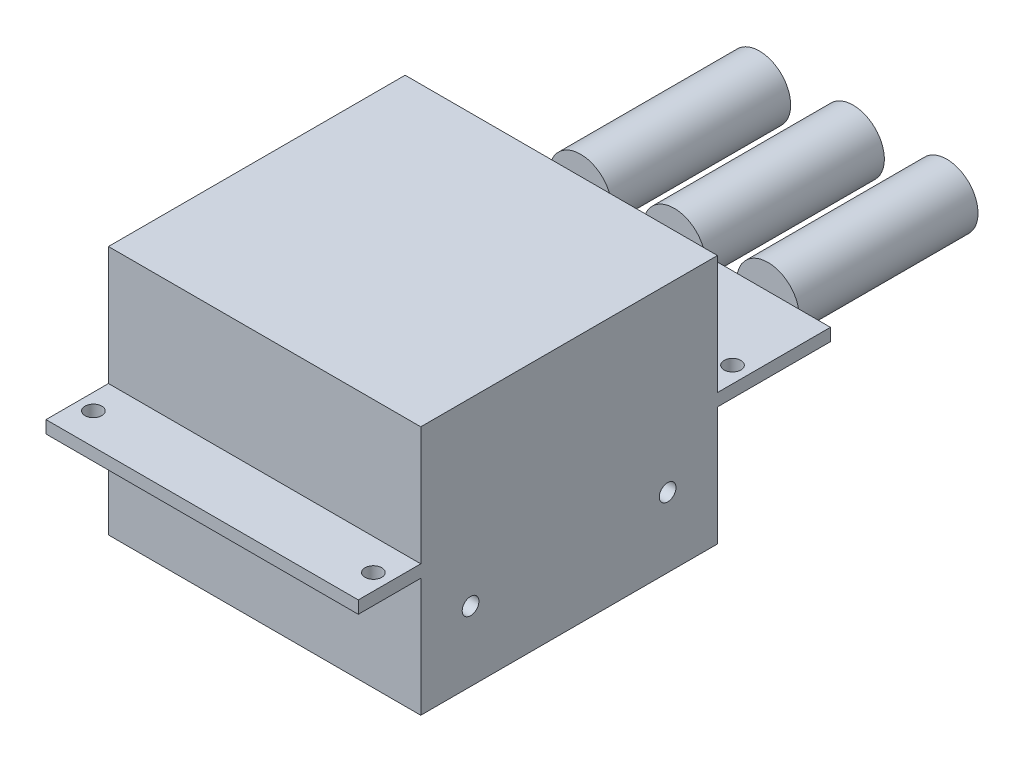
from build123d import *

# Parameters (mm, degrees)
SKETCH1_W               = 63.5
SKETCH1_H               = 50.8
BOSS_EXTRUDE1_DEPTH     = 96
SKETCH2_R               = 6.35
BOSS_EXTRUDE5_DEPTH     = 36.36
SKETCH3_W               = 12.7
SKETCH3_H               = 24.13
SKETCH3_W_2             = 22.975
CUT_EXTRUDE1_DEPTH      = 64.5
SKETCH4_R               = 1.7
CUT_EXTRUDE2_DEPTH      = 2.54
MIRROR3_COPY_1_SKETCH_R = 1.7
MIRROR3_COPY_1_DEPTH    = 2.54
SKETCH5_R               = 1.7
CUT_EXTRUDE3_DEPTH      = 64.5


with BuildPart() as part:
    # Sketch1 → Boss-Extrude1 (new body)
    with BuildSketch(Plane.XY):
        Rectangle(SKETCH1_W, SKETCH1_H)
    extrude(amount=-BOSS_EXTRUDE1_DEPTH)

    # Sketch2 → Boss-Extrude5 (add)
    with BuildSketch(Plane(origin=(0, 0, -96), x_dir=(-1, 0, 0), z_dir=(0, 0, -1))):
        Circle(SKETCH2_R)
        with Locations((-19.05, 0)):
            Circle(SKETCH2_R)
        with Locations((19.05, 0)):
            Circle(SKETCH2_R)
    extrude(amount=BOSS_EXTRUDE5_DEPTH)

    # Sketch3 → Cut-Extrude1 (cut, through all)
    with BuildSketch(Plane(origin=(31.75, 0, 0), x_dir=(0, 0, -1), z_dir=(1, 0, 0))):
        with Locations((6.35, -13.335)):
            Rectangle(SKETCH3_W, SKETCH3_H)
        with Locations((84.5125, -13.335)):
            Rectangle(SKETCH3_W_2, SKETCH3_H)
    cut_extrude1 = extrude(amount=-CUT_EXTRUDE1_DEPTH, mode=Mode.SUBTRACT)

    # Mirror1: Cut-Extrude1 across plane
    add(cut_extrude1.mirror(Plane.ZX), mode=Mode.SUBTRACT)

    # Sketch4 → Cut-Extrude2 (cut)
    with BuildSketch(Plane(origin=(0, 1.27, 0), x_dir=(1, 0, 0), z_dir=(0, 1, 0))):
        with Locations((-28.4625, 79.375)):
            Circle(SKETCH4_R)
    cut_extrude2 = extrude(amount=-CUT_EXTRUDE2_DEPTH, mode=Mode.SUBTRACT)

    # Mirror2: Cut-Extrude2 across plane
    add(cut_extrude2.mirror(Plane(origin=(0, 0, 0), x_dir=(0, 0, 1), z_dir=(1, 0, 0))), mode=Mode.SUBTRACT)

    # Mirror3: Cut-Extrude2 across plane
    add(cut_extrude2.mirror(Plane(origin=(0, 0, -42.8625), x_dir=(1, 0, 0), z_dir=(0, 0, -1))), mode=Mode.SUBTRACT)

    # Mirror3 copy 1 sketch → Mirror3 copy 1 (cut)
    with BuildSketch(Plane(origin=(0, 1.27, -85.725), x_dir=(-1, 0, 0), z_dir=(0, 1, 0))):
        with Locations((-28.4625, 79.375)):
            Circle(MIRROR3_COPY_1_SKETCH_R)
    extrude(amount=-MIRROR3_COPY_1_DEPTH, mode=Mode.SUBTRACT)

    # Sketch5 → Cut-Extrude3 (cut, through all)
    with BuildSketch(Plane(origin=(31.75, 0, 0), x_dir=(0, 0, -1), z_dir=(1, 0, 0))):
        with Locations((22.826875, -11.225)):
            Circle(SKETCH5_R)
    cut_extrude3 = extrude(amount=-CUT_EXTRUDE3_DEPTH, mode=Mode.SUBTRACT)

    # Mirror4: Cut-Extrude3 across plane
    add(cut_extrude3.mirror(Plane(origin=(0, 0, -42.8625), x_dir=(1, 0, 0), z_dir=(0, 0, -1))), mode=Mode.SUBTRACT)


solid = part.part
